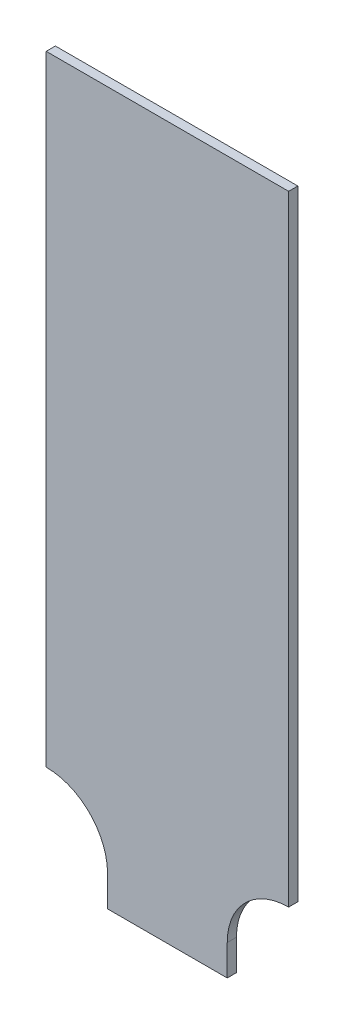
from build123d import *

# Parameters (mm, degrees)
EXTRUSION1_DEPTH = 3


with BuildPart() as part:
    # Esquisse1 → Extrusion1 (new body)
    with BuildSketch(Plane.XY):
        with BuildLine():
            Line((39.5, 232), (-39.5, 232))
            Line((-39.5, 232), (-39.5, 30))
            ThreePointArc((-39.5, 30), (-25.357864376, 24.142135624), (-19.5, 10))
            Line((-19.5, 10), (-19.5, 0))
            Line((-19.5, 0), (19.5, 0))
            Line((19.5, 0), (19.5, 10))
            ThreePointArc((19.5, 10), (25.357864376, 24.142135624), (39.5, 30))
            Line((39.5, 30), (39.5, 232))
        make_face()
    extrude(amount=EXTRUSION1_DEPTH)


solid = part.part
